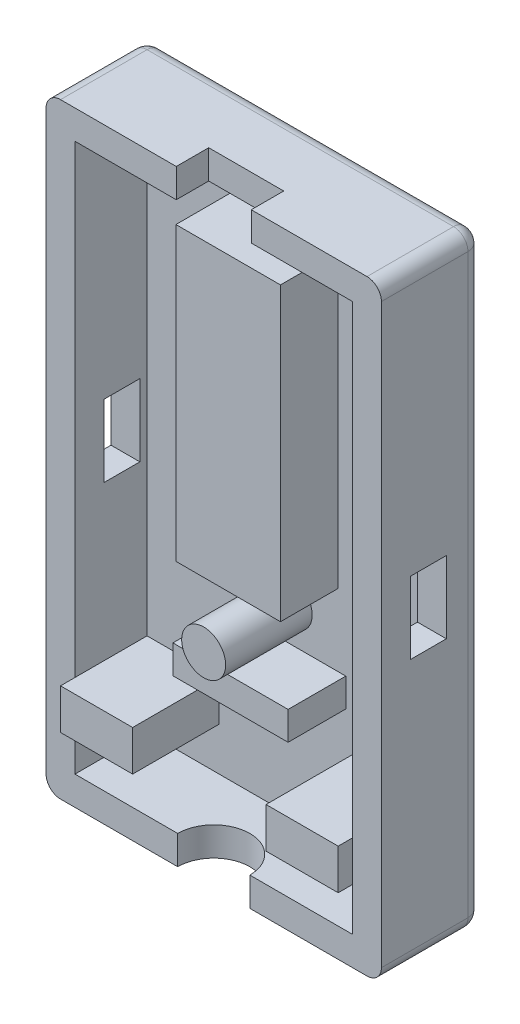
from build123d import *

# Parameters (mm, degrees)
SKETCH1_W           = 23.25
SKETCH1_H           = 42
BOSS_EXTRUDE1_DEPTH = 2
SKETCH2_W           = 23.25
SKETCH2_H           = 42
SKETCH2_W_2         = 19.25
SKETCH2_H_2         = 38
BOSS_EXTRUDE2_DEPTH = 5
SKETCH3_R           = 1.525
SKETCH3_W           = 5
SKETCH3_H           = 2.8
BOSS_EXTRUDE3_DEPTH = 6
SKETCH4_W           = 7.25
SKETCH4_H           = 20.225
SKETCH4_W_2         = 7.988530752
SKETCH4_H_2         = 1.975
BOSS_EXTRUDE4_DEPTH = 4
SKETCH5_W           = 5.2
SKETCH5_H           = 4.5
CUT_EXTRUDE1_DEPTH  = 3
CUT_EXTRUDE3_DEPTH  = 3
CUT_EXTRUDE4_DEPTH  = 3
CUT_EXTRUDE5_DEPTH  = 3
FILLET1_R           = 1


with BuildPart() as part:
    # Sketch1 → Boss-Extrude1 (new body)
    with BuildSketch(Plane.XY):
        Rectangle(SKETCH1_W, SKETCH1_H)
    extrude(amount=BOSS_EXTRUDE1_DEPTH)

    # Sketch2 → Boss-Extrude2 (add)
    with BuildSketch(Plane.XY.offset(2)):
        Rectangle(SKETCH2_W, SKETCH2_H)
        Rectangle(SKETCH2_W_2, SKETCH2_H_2, mode=Mode.SUBTRACT)
    extrude(amount=BOSS_EXTRUDE2_DEPTH)

    # Sketch3 → Boss-Extrude3 (add)
    with BuildSketch(Plane.XY.offset(2)):
        with Locations((0.3, -6.225)):
            Circle(SKETCH3_R)
        with Locations((-7.125, -14.6)):
            Rectangle(SKETCH3_W, SKETCH3_H)
        with Locations((7.125, -14.6)):
            Rectangle(SKETCH3_W, SKETCH3_H)
    extrude(amount=BOSS_EXTRUDE3_DEPTH)

    # Sketch4 → Boss-Extrude4 (add)
    with BuildSketch(Plane.XY.offset(2)):
        with Locations((0, 6.3875)):
            Rectangle(SKETCH4_W, SKETCH4_H)
        with Locations((0.159770615, -9.7125)):
            Rectangle(SKETCH4_W_2, SKETCH4_H_2)
    extrude(amount=BOSS_EXTRUDE4_DEPTH)

    # Sketch5 → Cut-Extrude1 (cut, through all)
    with BuildSketch(Plane.XZ.offset(-19)):
        with Locations((0, 7)):
            Rectangle(SKETCH5_W, SKETCH5_H)
    extrude(amount=-CUT_EXTRUDE1_DEPTH, mode=Mode.SUBTRACT)

    # Sketch6 → Cut-Extrude3 (cut, through all)
    with BuildSketch(Plane(origin=(0, -19, 0), x_dir=(1, 0, 0), z_dir=(0, 1, 0))):
        with BuildLine():
            Line((-2.5, -7), (2.5, -7))
            ThreePointArc((2.5, -7), (0, -4.5), (-2.5, -7))
        make_face()
    extrude(amount=-CUT_EXTRUDE3_DEPTH, mode=Mode.SUBTRACT)

    # Sketch7 → Cut-Extrude4 (cut, through all)
    with BuildSketch(Plane(origin=(-9.625, 0, 0), x_dir=(0, 0, -1), z_dir=(1, 0, 0))):
        Polygon((-2.5, 0), (-2.5, 2.5), (-5, 2.5), (-5, -2.5), (-2.5, -2.5), align=None)
    extrude(amount=-CUT_EXTRUDE4_DEPTH, mode=Mode.SUBTRACT)

    # Sketch8 → Cut-Extrude5 (cut, through all)
    with BuildSketch(Plane.ZY.offset(-9.625)):
        Polygon((2.5, 0), (2.5, -2.5), (5, -2.5), (5, 2.5), (2.5, 2.5), align=None)
    extrude(amount=-CUT_EXTRUDE5_DEPTH, mode=Mode.SUBTRACT)

    # Fillet1
    fillet1_edges = [part.edges().sort_by_distance(p)[0] for p in [
        (0, -21, 0),
        (-11.625, 0, 0),
        (0, 21, 0),
        (11.625, 0, 0),
        (11.625, -21, 3.5),
        (-11.625, -21, 3.5),
        (-11.625, 21, 3.5),
        (11.625, 21, 3.5),
    ]]
    fillet(fillet1_edges, radius=FILLET1_R)


solid = part.part
